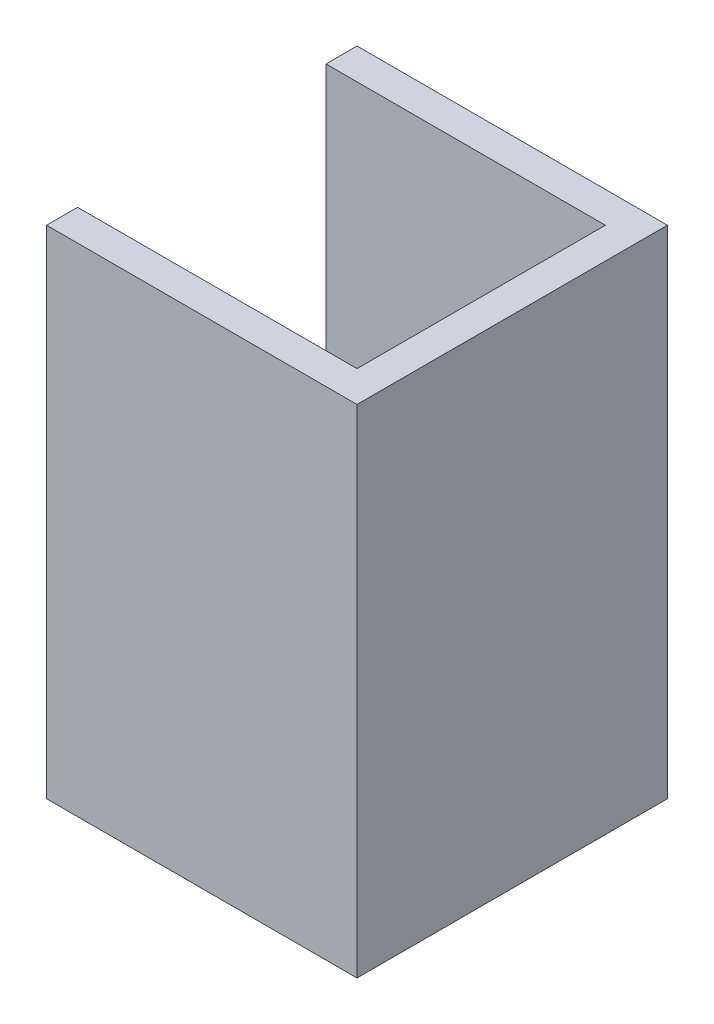
from build123d import *

# Parameters (mm, degrees)
BOSS_EXTRUDE1_DEPTH = 40


with BuildPart() as part:
    # Sketch1 → Boss-Extrude1 (new body)
    with BuildSketch(Plane(origin=(0, 0, 0), x_dir=(1, 0, 0), z_dir=(0, 1, 0))):
        Polygon((-12.5, 10), (-12.5, 12.5), (12.5, 12.5), (12.5, -12.5), (-12.5, -12.5), (-12.5, -10), (10, -10), (10, 10), align=None)
    extrude(amount=BOSS_EXTRUDE1_DEPTH)


solid = part.part
